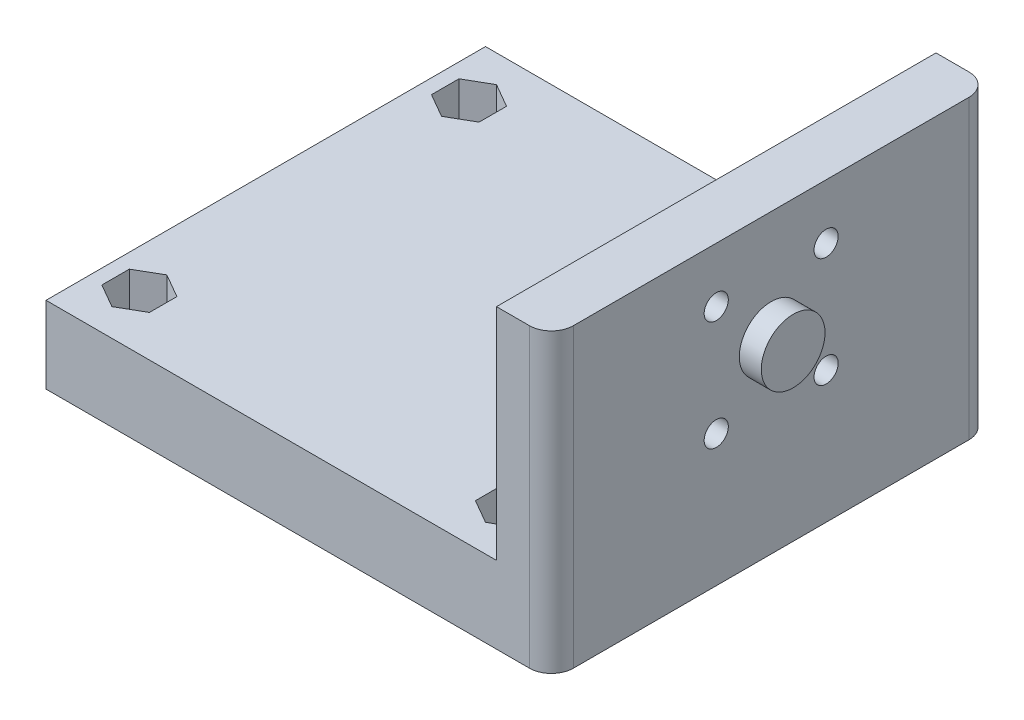
from build123d import *

# Parameters (mm, degrees)
ESQUISSE1_W             = 5
ESQUISSE1_H             = 40
BOSS_EXTRU_1_DEPTH      = 27
ESQUISSE2_W             = 40
ESQUISSE2_H             = 7
BOSS_EXTRU_2_DEPTH      = 41
CONG_1_R                = 2
ENL_V_MAT_EXTRU_1_REACH = 48
ESQUISSE4_R             = 1.1
ESQUISSE5_R             = 2.9
BOSS_EXTRU_3_DEPTH      = 2
ENL_V_MAT_EXTRU_3_DEPTH = 3
ESQUISSE9_R             = 1.1
ENL_V_MAT_EXTRU_5_DEPTH = 8
ENL_V_MAT_EXTRU_4_DEPTH = 4


with BuildPart() as part:
    # Esquisse1 → Boss.-Extru.1 (new body)
    with BuildSketch(Plane(origin=(0, 0, 0), x_dir=(1, 0, 0), z_dir=(0, 1, 0))):
        with Locations((-2.5, 0)):
            Rectangle(ESQUISSE1_W, ESQUISSE1_H)
    extrude(amount=-BOSS_EXTRU_1_DEPTH)

    # Esquisse2 → Boss.-Extru.2 (add)
    with BuildSketch(Plane.ZY.offset(5)):
        with Locations((0, -23.5)):
            Rectangle(ESQUISSE2_W, ESQUISSE2_H)
    extrude(amount=BOSS_EXTRU_2_DEPTH)

    # Congé1
    cong_1_edges = [part.edges().sort_by_distance(p)[0] for p in [
        (0, -13.5, 20),
        (0, -13.5, -20),
    ]]
    fillet(cong_1_edges, radius=CONG_1_R)

    # Esquisse4 → Enlèv. mat.-Extru.1 (cut, up to next)
    with BuildSketch(Plane(origin=(0, 0, 0), x_dir=(0, 0, -1), z_dir=(1, 0, 0)), mode=Mode.PRIVATE) as enl_v_mat_extru_1_sk1:
        with Locations((-5, -5)):
            Circle(ESQUISSE4_R)
    enl_v_mat_extru_1_tool1 = extrude(enl_v_mat_extru_1_sk1.sketch, amount=-ENL_V_MAT_EXTRU_1_REACH, mode=Mode.PRIVATE) & part.part
    add(enl_v_mat_extru_1_tool1.solids().sort_by_distance((0, -5, 5))[0], mode=Mode.SUBTRACT)
    # Esquisse4 → Enlèv. mat.-Extru.1 (cut, up to next)
    with BuildSketch(Plane(origin=(0, 0, 0), x_dir=(0, 0, -1), z_dir=(1, 0, 0)), mode=Mode.PRIVATE) as enl_v_mat_extru_1_sk2:
        with Locations((5, -5)):
            Circle(ESQUISSE4_R)
    enl_v_mat_extru_1_tool2 = extrude(enl_v_mat_extru_1_sk2.sketch, amount=-ENL_V_MAT_EXTRU_1_REACH, mode=Mode.PRIVATE) & part.part
    add(enl_v_mat_extru_1_tool2.solids().sort_by_distance((0, -5, -5))[0], mode=Mode.SUBTRACT)
    # Esquisse4 → Enlèv. mat.-Extru.1 (cut, up to next)
    with BuildSketch(Plane(origin=(0, 0, 0), x_dir=(0, 0, -1), z_dir=(1, 0, 0)), mode=Mode.PRIVATE) as enl_v_mat_extru_1_sk3:
        with Locations((-5, -15)):
            Circle(ESQUISSE4_R)
    enl_v_mat_extru_1_tool3 = extrude(enl_v_mat_extru_1_sk3.sketch, amount=-ENL_V_MAT_EXTRU_1_REACH, mode=Mode.PRIVATE) & part.part
    add(enl_v_mat_extru_1_tool3.solids().sort_by_distance((0, -15, 5))[0], mode=Mode.SUBTRACT)
    # Esquisse4 → Enlèv. mat.-Extru.1 (cut, up to next)
    with BuildSketch(Plane(origin=(0, 0, 0), x_dir=(0, 0, -1), z_dir=(1, 0, 0)), mode=Mode.PRIVATE) as enl_v_mat_extru_1_sk4:
        with Locations((5, -15)):
            Circle(ESQUISSE4_R)
    enl_v_mat_extru_1_tool4 = extrude(enl_v_mat_extru_1_sk4.sketch, amount=-ENL_V_MAT_EXTRU_1_REACH, mode=Mode.PRIVATE) & part.part
    add(enl_v_mat_extru_1_tool4.solids().sort_by_distance((0, -15, -5))[0], mode=Mode.SUBTRACT)

    # Esquisse5 → Boss.-Extru.3 (add)
    with BuildSketch(Plane(origin=(0, 0, 0), x_dir=(0, 0, -1), z_dir=(1, 0, 0))):
        with Locations((0, -10)):
            Circle(ESQUISSE5_R)
    extrude(amount=BOSS_EXTRU_3_DEPTH)

    # Esquisse7 → Enlèv. mat.-Extru.3 (cut)
    with BuildSketch(Plane.ZY.offset(5)):
        Polygon((-3.75, -7.165063509), (-2.5, -5), (-3.75, -2.834936491), (-6.25, -2.834936491), (-7.5, -5), (-6.25, -7.165063509), align=None)
        Polygon((3.75, -2.834936491), (2.5, -5), (3.75, -7.165063509), (6.25, -7.165063509), (7.5, -5), (6.25, -2.834936491), align=None)
        Polygon((-3.75, -17.165063509), (-2.5, -15), (-3.75, -12.834936491), (-6.25, -12.834936491), (-7.5, -15), (-6.25, -17.165063509), align=None)
        Polygon((7.5, -15), (6.25, -12.834936491), (3.75, -12.834936491), (2.5, -15), (3.75, -17.165063509), (6.25, -17.165063509), align=None)
    extrude(amount=-ENL_V_MAT_EXTRU_3_DEPTH, mode=Mode.SUBTRACT)

    # Esquisse9 → Enlèv. mat.-Extru.5 (cut, through all)
    with BuildSketch(Plane(origin=(0, -20, 0), x_dir=(1, 0, 0), z_dir=(0, 1, 0))):
        with Locations(Location((-8.5, 15, 0), (0, 0, 270))):  # turned: the seam where the file's is
            Circle(ESQUISSE9_R)
        with Locations(Location((-8.5, -15, 0), (0, 0, 270))):  # turned: the seam where the file's is
            Circle(ESQUISSE9_R)
        with Locations(Location((-42.5, -15, 0), (0, 0, 270))):  # turned: the seam where the file's is
            Circle(ESQUISSE9_R)
        with Locations(Location((-42.5, 15, 0), (0, 0, 270))):  # turned: the seam where the file's is
            Circle(ESQUISSE9_R)
    extrude(amount=-ENL_V_MAT_EXTRU_5_DEPTH, mode=Mode.SUBTRACT)

    # Esquisse8 → Enlèv. mat.-Extru.4 (cut)
    with BuildSketch(Plane(origin=(0, -20, 0), x_dir=(1, 0, 0), z_dir=(0, 1, 0))):
        Polygon((-10.665063509, 13.75), (-8.5, 12.5), (-6.334936491, 13.75), (-6.334936491, 16.25), (-8.5, 17.5), (-10.665063509, 16.25), align=None)
        Polygon((-10.665063509, -16.25), (-8.5, -17.5), (-6.334936491, -16.25), (-6.334936491, -13.75), (-8.5, -12.5), (-10.665063509, -13.75), align=None)
        Polygon((-44.665063509, -16.25), (-42.5, -17.5), (-40.334936491, -16.25), (-40.334936491, -13.75), (-42.5, -12.5), (-44.665063509, -13.75), align=None)
        Polygon((-42.5, 12.5), (-40.334936491, 13.75), (-40.334936491, 16.25), (-42.5, 17.5), (-44.665063509, 16.25), (-44.665063509, 13.75), align=None)
    extrude(amount=-ENL_V_MAT_EXTRU_4_DEPTH, mode=Mode.SUBTRACT)


solid = part.part
